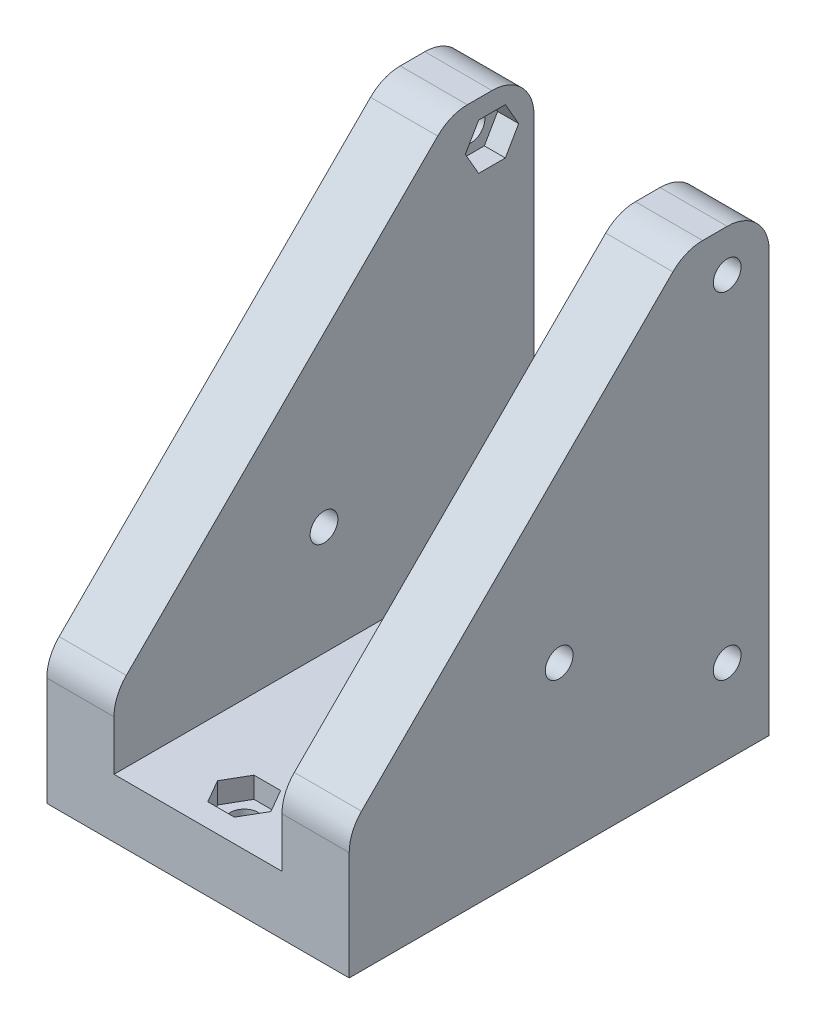
from build123d import *

# Parameters (mm, degrees)
P_IDAT_VYSUNUT_M1_DEPTH  = 50
ZKOSEN_1_SIZE            = 40
ZKOSEN_2_SIZE            = 40
SKICA2_R                 = 1.65
ODEBRAT_VYSUNUT_M1_DEPTH = 37
ZAOBLIT1_R               = 5
ODEBRAT_VYSUNUT_M2_DEPTH = 2.5
ODEBRAT_VYSUNUT_M3_DEPTH = 2.5
SKICA7_R                 = 1.65
ODEBRAT_VYSUNUT_M4_DEPTH = 56
ODEBRAT_VYSUNUT_M5_DEPTH = 2.5


with BuildPart() as part:
    # Skica1 → Přidat vysunutím1 (new body)
    with BuildSketch(Plane.XY):
        Polygon((0, 0), (0, 55), (8, 55), (8, 7), (28, 7), (28, 55), (36, 55), (36, 0), align=None)
    extrude(amount=P_IDAT_VYSUNUT_M1_DEPTH)

    # Zkosení1
    zkosen_1_edges = [part.edges().sort_by_distance(p)[0] for p in [
        (32, 55, 50),
    ]]
    chamfer(zkosen_1_edges, length=ZKOSEN_1_SIZE)

    # Zkosení2
    zkosen_2_edges = [part.edges().sort_by_distance(p)[0] for p in [
        (4, 55, 50),
    ]]
    chamfer(zkosen_2_edges, length=ZKOSEN_2_SIZE)

    # Skica2 → Odebrat vysunutím1 (cut, through all)
    with BuildSketch(Plane(origin=(36, 0, 0), x_dir=(0, 0, -1), z_dir=(1, 0, 0))):
        with Locations((-5, 50)):
            Circle(SKICA2_R)
        with Locations((-5, 10)):
            Circle(SKICA2_R)
        with Locations((-25, 20)):
            Circle(SKICA2_R)
    extrude(amount=-ODEBRAT_VYSUNUT_M1_DEPTH, mode=Mode.SUBTRACT)

    # Zaoblit1
    zaoblit1_edges = [part.edges().sort_by_distance(p)[0] for p in [
        (32, 15, 50),
        (32, 55, 10),
        (4, 15, 50),
        (4, 55, 10),
        (4, 55, 0),
        (32, 55, 0),
    ]]
    fillet(zaoblit1_edges, radius=ZAOBLIT1_R)

    # Skica3 → Odebrat vysunutím2 (cut)
    with BuildSketch(Plane.ZY.offset(-28)):
        Polygon((6.58771324, 52.75), (3.41228676, 52.75), (1.824573519, 50), (3.41228676, 47.25), (6.58771324, 47.25), (8.175426481, 50), align=None)
        Polygon((6.58771324, 12.75), (3.41228676, 12.75), (1.824573519, 10), (3.41228676, 7.25), (6.58771324, 7.25), (8.175426481, 10), align=None)
    extrude(amount=-ODEBRAT_VYSUNUT_M2_DEPTH, mode=Mode.SUBTRACT)

    # Skica6 → Odebrat vysunutím3 (cut)
    with BuildSketch(Plane(origin=(8, 0, 0), x_dir=(0, 0, -1), z_dir=(1, 0, 0))):
        Polygon((-3.41228676, 52.75), (-6.58771324, 52.75), (-8.175426481, 50), (-6.58771324, 47.25), (-3.41228676, 47.25), (-1.824573519, 50), align=None)
        Polygon((-3.41228676, 12.75), (-6.58771324, 12.75), (-8.175426481, 10), (-6.58771324, 7.25), (-3.41228676, 7.25), (-1.824573519, 10), align=None)
    extrude(amount=-ODEBRAT_VYSUNUT_M3_DEPTH, mode=Mode.SUBTRACT)

    # Skica7 → Odebrat vysunutím4 (cut, through all)
    with BuildSketch(Plane.XZ):
        with Locations((18, 44.5)):
            Circle(SKICA7_R)
        with Locations((18, 25.45)):
            Circle(SKICA7_R)
        with Locations((18, 6.4)):
            Circle(SKICA7_R)
    extrude(amount=-ODEBRAT_VYSUNUT_M4_DEPTH, mode=Mode.SUBTRACT)

    # Skica8 → Odebrat vysunutím5 (cut)
    with BuildSketch(Plane(origin=(0, 7, 0), x_dir=(1, 0, 0), z_dir=(0, 1, 0))):
        Polygon((14.824573519, -6.4), (16.41228676, -9.15), (19.58771324, -9.15), (21.175426481, -6.4), (19.58771324, -3.65), (16.41228676, -3.65), align=None)
        Polygon((14.824573519, -25.45), (16.41228676, -28.2), (19.58771324, -28.2), (21.175426481, -25.45), (19.58771324, -22.7), (16.41228676, -22.7), align=None)
        Polygon((14.824573519, -44.5), (16.41228676, -47.25), (19.58771324, -47.25), (21.175426481, -44.5), (19.58771324, -41.75), (16.41228676, -41.75), align=None)
    extrude(amount=-ODEBRAT_VYSUNUT_M5_DEPTH, mode=Mode.SUBTRACT)


solid = part.part
